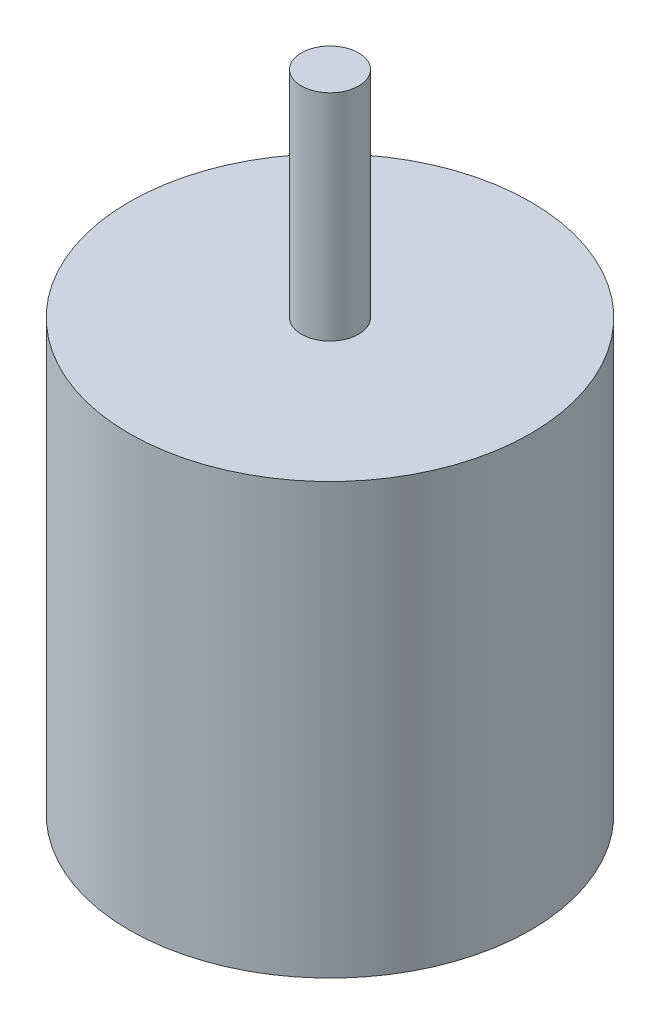
from build123d import *

# Parameters (mm, degrees)
SKETCH1_R           = 14
BOSS_EXTRUDE1_DEPTH = 30
SKETCH2_R           = 2
BOSS_EXTRUDE2_DEPTH = 15


with BuildPart() as part:
    # Sketch1 → Boss-Extrude1 (new body)
    with BuildSketch(Plane(origin=(0, 0, 0), x_dir=(1, 0, 0), z_dir=(0, 1, 0))):
        Circle(SKETCH1_R)
    extrude(amount=BOSS_EXTRUDE1_DEPTH)

    # Sketch2 → Boss-Extrude2 (add)
    with BuildSketch(Plane(origin=(0, 30, 0), x_dir=(1, 0, 0), z_dir=(0, 1, 0))):
        Circle(SKETCH2_R)
    extrude(amount=BOSS_EXTRUDE2_DEPTH)


solid = part.part
